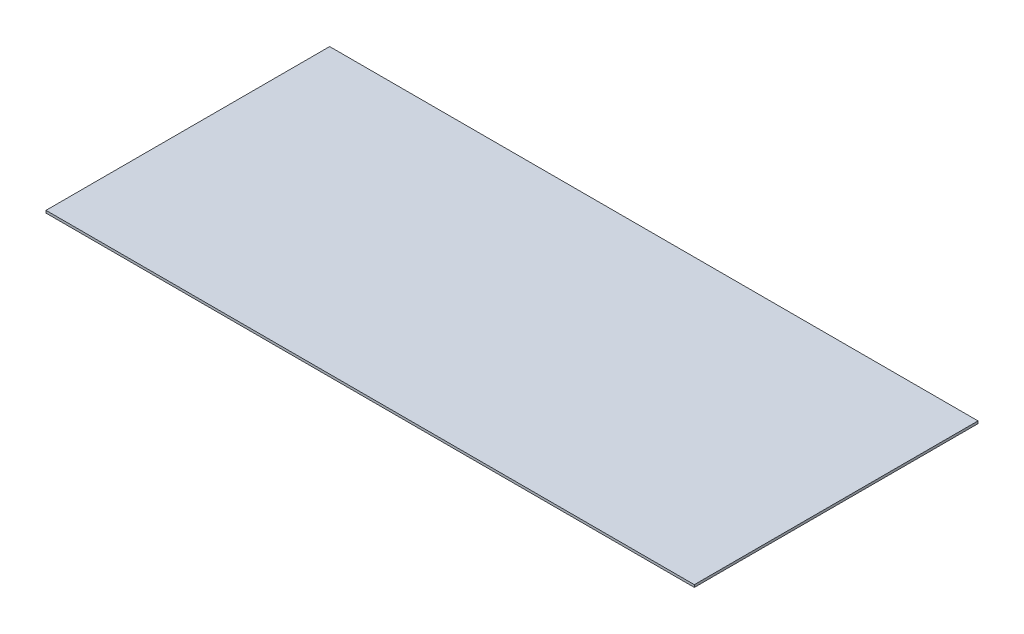
from build123d import *

# Parameters (mm, degrees)
SKETCH13_W          = 800
SKETCH13_H          = 350
BOSS_EXTRUDE1_DEPTH = 3


with BuildPart() as part:
    # Sketch13 → Boss-Extrude1 (new body)
    with BuildSketch(Plane(origin=(0, 0, 0), x_dir=(1, 0, 0), z_dir=(0, 1, 0))):
        Rectangle(SKETCH13_W, SKETCH13_H)
    extrude(amount=BOSS_EXTRUDE1_DEPTH)


solid = part.part
